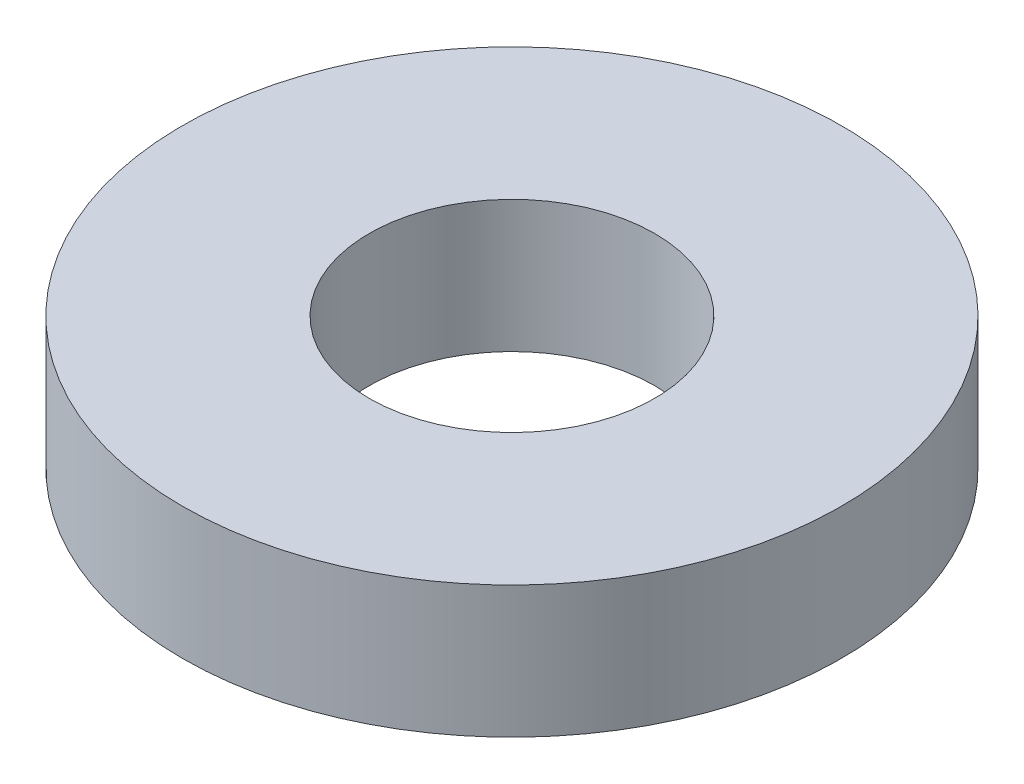
from build123d import *

# Parameters (mm, degrees)
SKETCH1_R           = 3.81
SKETCH1_R_2         = 1.651
BOSS_EXTRUDE1_DEPTH = 1.524


with BuildPart() as part:
    # Sketch1 → Boss-Extrude1 (new body)
    with BuildSketch(Plane(origin=(0, 0, 0), x_dir=(1, 0, 0), z_dir=(0, 1, 0))):
        Circle(SKETCH1_R)
        Circle(SKETCH1_R_2, mode=Mode.SUBTRACT)
    extrude(amount=BOSS_EXTRUDE1_DEPTH)


solid = part.part
